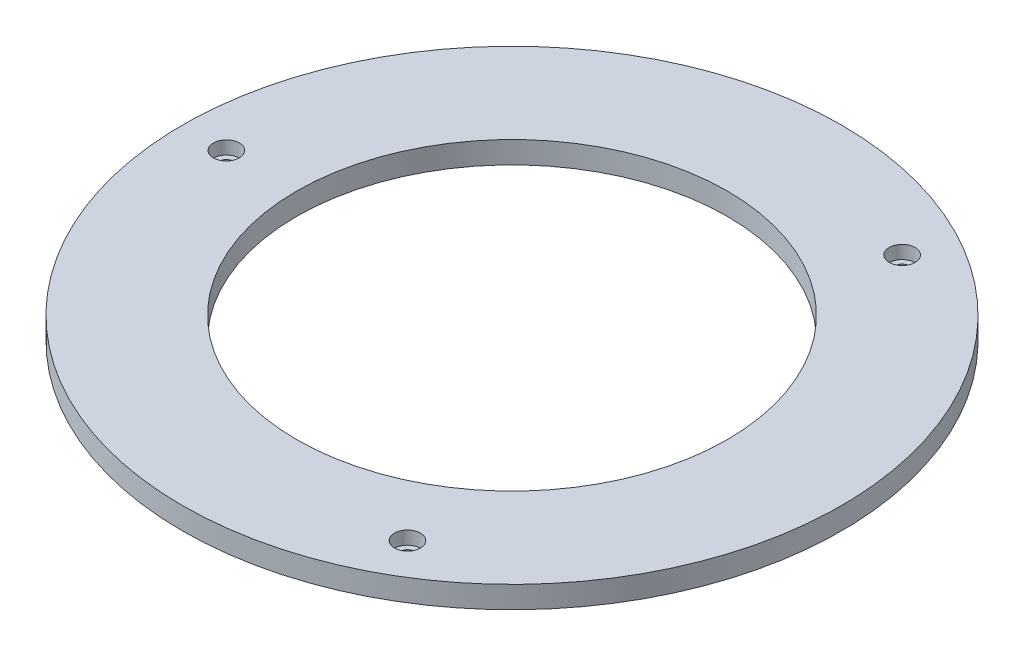
from build123d import *

# Parameters (mm, degrees)
CROQUIS1_R              = 75
CROQUIS1_R_2            = 49
SALIENTE_EXTRUIR1_DEPTH = 5
CROQUIS2_R              = 1.7
CORTAR_EXTRUIR1_DEPTH   = 5
CROQUIS3_R              = 2.95
CORTAR_EXTRUIR2_DEPTH   = 3
MATRIZC1_COUNT          = 3


with BuildPart() as part:
    # Croquis1 → Saliente-Extruir1 (new body)
    with BuildSketch(Plane(origin=(0, 0, 0), x_dir=(1, 0, 0), z_dir=(0, 1, 0))):
        Circle(CROQUIS1_R)
        Circle(CROQUIS1_R_2, mode=Mode.SUBTRACT)
    extrude(amount=SALIENTE_EXTRUIR1_DEPTH)

    # Croquis2 → Cortar-Extruir1 (cut)
    with BuildSketch(Plane(origin=(0, 5, 0), x_dir=(1, 0, 0), z_dir=(0, 1, 0))):
        with Locations((-65, 0)):
            Circle(CROQUIS2_R)
    cortar_extruir1 = extrude(amount=-CORTAR_EXTRUIR1_DEPTH, mode=Mode.SUBTRACT)

    # Croquis3 → Cortar-Extruir2 (cut)
    with BuildSketch(Plane(origin=(0, 5, 0), x_dir=(1, 0, 0), z_dir=(0, 1, 0))):
        with Locations((-65, 0)):
            Circle(CROQUIS3_R)
    cortar_extruir2 = extrude(amount=-CORTAR_EXTRUIR2_DEPTH, mode=Mode.SUBTRACT)

    # MatrizC1: Cortar-Extruir1, Cortar-Extruir2 ×3 about axis
    matrizc1_axis = Axis((0, 0, 0), (0, 1, 0))
    for i in range(1, MATRIZC1_COUNT):
        add(cortar_extruir1.rotate(matrizc1_axis, i * 360 / MATRIZC1_COUNT), mode=Mode.SUBTRACT)
        add(cortar_extruir2.rotate(matrizc1_axis, i * 360 / MATRIZC1_COUNT), mode=Mode.SUBTRACT)


solid = part.part
